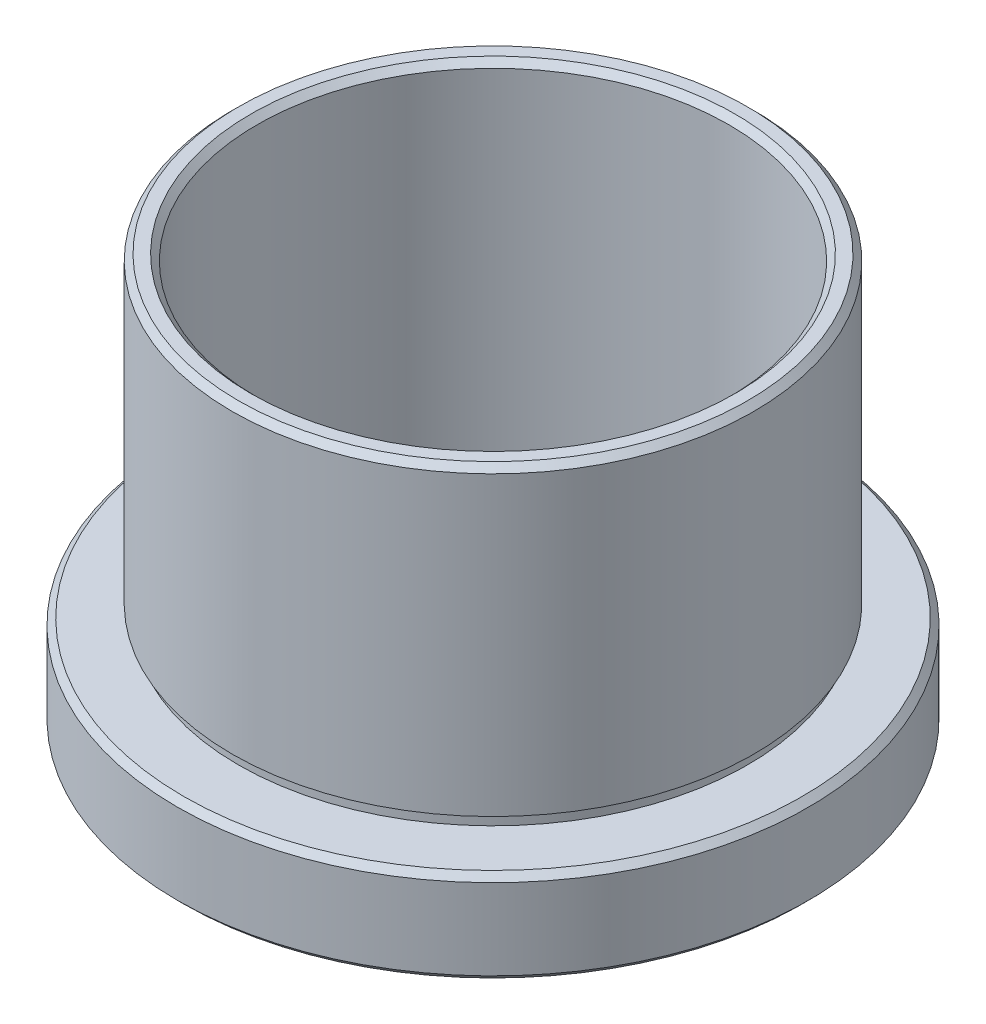
from build123d import *


with BuildPart() as part:
    # 草图1 → 旋转2 (revolve)
    with BuildSketch(Plane.XY, mode=Mode.PRIVATE) as revolve_2_sk:
        Polygon((19.5, 27.042854175), (20.5, 27.042854175), (21, 26.542854175), (21, 2.642854175), (20.5, 2.642854175), (20.5, 1.642854175), (24.9, 1.642854175), (25.4, 1.142854175), (25.4, -5.357145825), (24.9, -5.857145825), (21.5, -5.857145825), (21, -5.357145825), (21, -1.357145825), (21.1, -1.357145825), (21.1, -0.357145825), (19, -0.357145825), (19, 26.542854175), align=None)
    revolve(revolve_2_sk.sketch.rotate(Axis((0, 44.598597745, 0), (0, -1, 0)), 90), axis=Axis((0, 44.598597745, 0), (0, -1, 0)))  # turned: the seam where the file's is


solid = part.part
